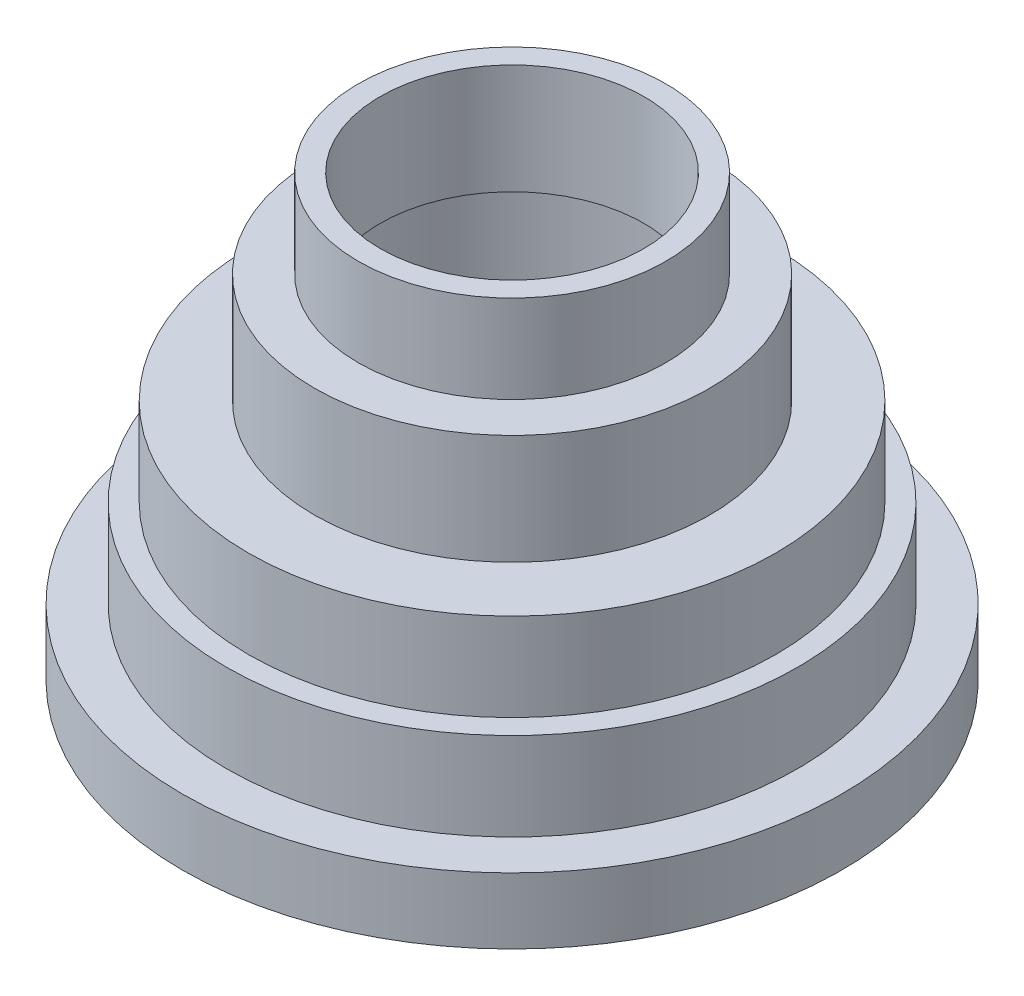
from build123d import *


with BuildPart() as part:
    # Sketch1 → Revolve1 (revolve)
    with BuildSketch(Plane.XY):
        Polygon((-75, -49.403669725), (-75, -34.403669725), (-65, -34.403669725), (-65, -14.403669725), (-60, -14.403669725), (-60, 5.596330275), (-45, 5.596330275), (-45, 30.596330275), (-35, 30.596330275), (-35, 50.596330275), (-30, 50.596330275), (-30, 25.596330275), (-40, 25.596330275), (-40, 0.596330275), (-55, 0.596330275), (-55, -19.403669725), (-60, -19.403669725), (-60, -39.403669725), (-70, -39.403669725), (-70, -49.403669725), align=None)
    revolve(axis=Axis((0, 50, 0), (0, -1, 0)))


solid = part.part
